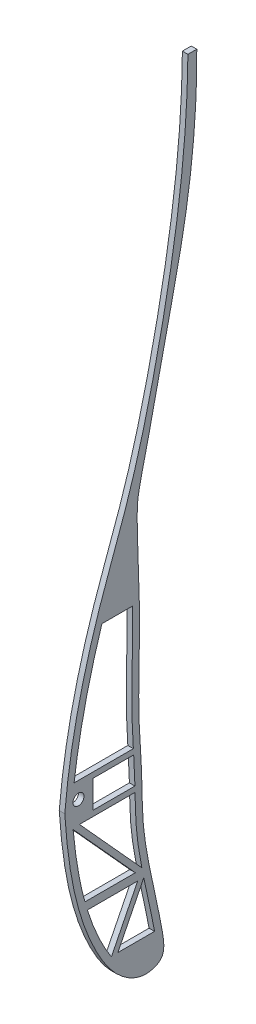
from build123d import *

# Parameters (mm, degrees)
RIB2_R              = 2
BOSS_EXTRUDE1_DEPTH = 2


with BuildPart() as part:
    # rib2 → Boss-Extrude1 (new body)
    with BuildSketch(Plane(origin=(0, 0, 0), x_dir=(0, 0, -1), z_dir=(1, 0, 0))):
        with BuildLine():
            Line((801.906188374, 590.408064711), (805.114959312, 590.408064711))
            add(Edge.make_bspline(
                [(757.334151871, 374.654040423), (758.488618024, 357.641582882), (761.828045075, 335.038149914), (776.364446292, 313.183311775), (785.880697371, 308.841980468), (791.313928595, 310.610251685), (793.075385029, 312.987941846), (793.337462447, 316.107743129), (791.041438182, 329.643146103), (787.955992365, 341.196605561), (785.204159751, 359.620713161), (785.453788795, 372.997065253), (783.431517771, 397.430131694), (785.247615348, 420.762517316), (783.053458863, 455.809656019), (784.46944524, 464.386743168), (788.132816832, 479.293540681), (793.242767846, 503.980467438), (802.540056937, 542.60535953), (805.258661067, 572.394099523), (805.114959312, 590.408064711)],
                knots=[0, 0, 0, 0, 0.100347506, 0.132199535, 0.149145767, 0.158795903, 0.160733945, 0.167660381, 0.175846517, 0.23440917, 0.246070128, 0.285135768, 0.310616456, 0.385264398, 0.441942427, 0.454032525, 0.506165375, 0.624061376, 0.777474311, 1, 1, 1, 1], degree=3))
            add(Edge.make_bspline(
                [(801.906188374, 590.408064711), (801.696580445, 560.152145616), (794.998743299, 516.437213249), (781.93695997, 464.922235889), (766.027657556, 424.310340528), (759.177489387, 395.318637871), (757.334151871, 374.654040423)],
                knots=[0, 0, 0, 0, 0.408825995, 0.598517714, 0.719267245, 1, 1, 1, 1], degree=3))
        make_face()
        with Locations((762.289499993, 376.641580619)):
            Circle(RIB2_R, mode=Mode.SUBTRACT)
        with BuildLine():
            Line((782.893255333, 343.385908236), (760.356317877, 368.210879977))
            add(Edge.make_bspline(
                [(760.356317877, 368.210879977), (760.645542865, 365.10832887), (761.297099334, 359.39979898), (762.685561286, 351.207948443), (763.890877386, 346.064289497), (764.603996251, 343.478926304), (764.629795024, 343.385908236)],
                knots=[0.01313003, 0.01313003, 0.01313003, 0.01313003, 0.031626349, 0.047245279, 0.062864209, 0.063447417, 0.063447417, 0.063447417, 0.063447417], degree=3))
            Line((764.629795024, 343.385908236), (782.893255333, 343.385908236))
        make_face(mode=Mode.SUBTRACT)
        with BuildLine():
            Line((785.235370081, 343.762046236), (762.664726398, 368.641580619))
            Line((762.664726398, 368.641580619), (782.775527245, 368.641580619))
            add(Edge.make_bspline(
                [(785.235370081, 343.762046236), (784.91173753, 345.435849463), (784.369480266, 348.412605531), (783.683400447, 352.846020065), (783.092319972, 358.350652793), (782.886598015, 363.619677576), (782.801054433, 367.500970974), (782.775527245, 368.641580619)],
                knots=[0.224345048, 0.224345048, 0.224345048, 0.224345048, 0.234672437, 0.242481902, 0.250291367, 0.265910297, 0.272429812, 0.272429812, 0.272429812, 0.272429812], degree=3))
        make_face(mode=Mode.SUBTRACT)
        with BuildLine():
            Line((783.737403403, 340.385908263), (774.220368213, 321.355424184))
            add(Edge.make_bspline(
                [(765.512588053, 340.385908263), (765.942062452, 339.008160638), (767.225549025, 335.196727707), (769.261685791, 330.291102646), (771.60894792, 325.640152406), (773.096725597, 323.059967565), (774.004343098, 321.674751511), (774.220368213, 321.355424184)],
                knots=[0.069750662, 0.069750662, 0.069750662, 0.069750662, 0.078483139, 0.094102069, 0.101911534, 0.109720999, 0.112105214, 0.112105214, 0.112105214, 0.112105214], degree=3))
            Line((765.512588053, 340.385908263), (783.737403403, 340.385908263))
        make_face(mode=Mode.SUBTRACT)
        with BuildLine():
            Line((767.571939027, 380.641580619), (767.571939027, 370.641580619))
            Line((767.571939027, 370.641580619), (782.729137506, 370.641580619))
            add(Edge.make_bspline(
                [(782.729137506, 370.641580619), (782.706435659, 371.563392329), (782.64381769, 373.84263601), (782.499614968, 377.160810261), (782.352274741, 379.579890207), (782.285482298, 380.641580619)],
                knots=[0.276245485, 0.276245485, 0.276245485, 0.276245485, 0.281529227, 0.289338692, 0.295444604, 0.295444604, 0.295444604, 0.295444604], degree=3))
            Line((782.285482298, 380.641580619), (767.571939027, 380.641580619))
        make_face(mode=Mode.SUBTRACT)
        with BuildLine():
            Line((776.543525523, 321.529397962), (789.845927053, 321.529397962))
            add(Edge.make_bspline(
                [(789.845927053, 321.529397962), (789.814167011, 321.699503823), (789.75042892, 322.038893566), (789.457737754, 323.580698572), (788.929454, 326.240421287), (788.149638114, 329.952624524), (787.332530562, 333.724036883), (786.588165074, 337.157851053), (786.125599329, 339.349407119), (785.929582763, 340.297979166)],
                knots=[0.178917784, 0.178917784, 0.178917784, 0.178917784, 0.179893967, 0.18087015, 0.187815648, 0.195625113, 0.203434578, 0.211244043, 0.217170107, 0.217170107, 0.217170107, 0.217170107], degree=3))
            Line((785.929582763, 340.297979166), (776.543525523, 321.529397962))
        make_face(mode=Mode.SUBTRACT)
        with BuildLine():
            Line((760.713816227, 382.641580619), (782.158524772, 382.641580619))
            add(Edge.make_bspline(
                [(782.158524772, 382.641580619), (782.009801347, 384.984999743), (781.532269832, 392.728796781), (781.601558597, 402.504492042), (781.812144771, 413.028444883), (781.889539879, 420.046613203), (781.856336874, 425.007877782), (781.822920812, 427.030653457), (781.814391399, 427.491820966)],
                knots=[0.299279435, 0.299279435, 0.299279435, 0.299279435, 0.312767087, 0.344004946, 0.359623876, 0.375242806, 0.383052271, 0.385336265, 0.385336265, 0.385336265, 0.385336265], degree=3))
            Line((781.814391399, 427.491820966), (770.786643098, 427.491820966))
            add(Edge.make_bspline(
                [(770.786643098, 427.491820966), (769.467056164, 423.338665257), (766.964736871, 414.770061406), (763.38044978, 399.851527626), (761.525068294, 389.014059476), (760.713816227, 382.641580619)],
                knots=[0.752167527, 0.752167527, 0.752167527, 0.752167527, 0.811772658, 0.874216708, 0.962264248, 0.962264248, 0.962264248, 0.962264248], degree=3))
        make_face(mode=Mode.SUBTRACT)
    extrude(amount=BOSS_EXTRUDE1_DEPTH)


solid = part.part
